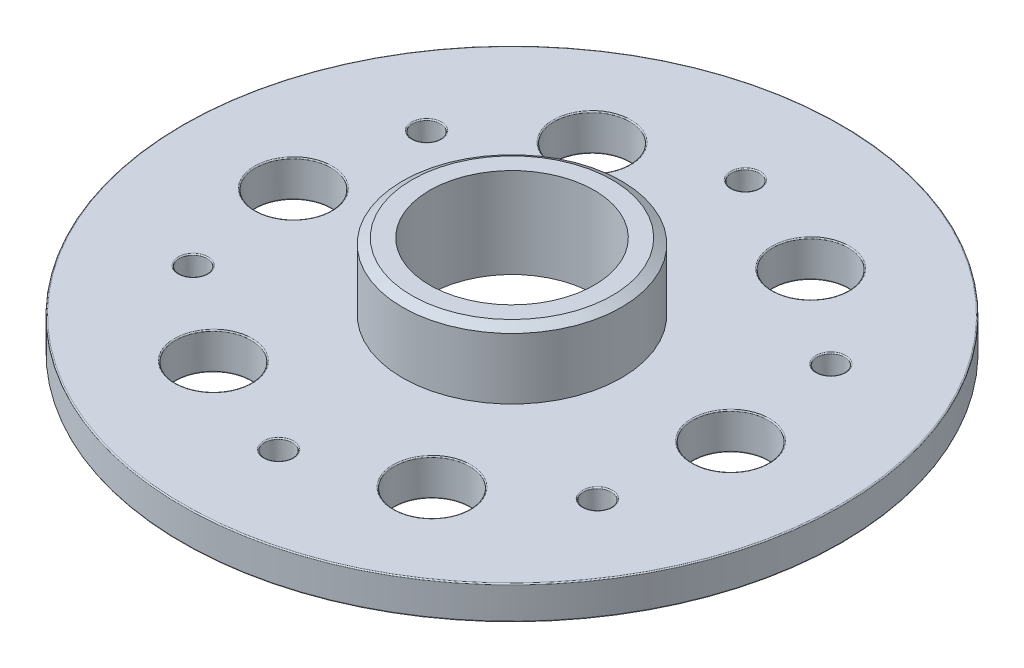
from build123d import *

# Parameters (mm, degrees)
SKETCH_3_R          = 15
CUT_EXTRUDE_2_DEPTH = 0.2
SKETCH_4_R          = 1.25
SKETCH_4_R_2        = 3.4
CUT_EXTRUDE_3_DEPTH = 10.3
FILLET_3_R          = 0.1


with BuildPart() as part:
    # Эскиз1 → Повернуть1 (revolve)
    with BuildSketch(Plane.XY):
        Polygon((-9.85, 14), (-9.85, 19.5), (-9.018203137, 20), (-7.4, 20), (-7.4, 11.9), (-9, 11.9), (-9, 10.7), (-24.5, 10.7), (-29.65, 11), (-29.65, 14), align=None)
    revolve(axis=Axis((0, 73.864195873, 0), (0, -1, 0)))

    # Эскиз3 → Вырез-Вытянуть2 (cut)
    with BuildSketch(Plane.XZ.offset(-10.7)):
        Circle(SKETCH_3_R)
    extrude(amount=-CUT_EXTRUDE_2_DEPTH, mode=Mode.SUBTRACT)

    # Эскиз4 → Вырез-Вытянуть3 (cut, through all)
    with BuildSketch(Plane.XZ.offset(-10.7)):
        with Locations((0, 21)):
            Circle(SKETCH_4_R)
        with Locations((18.186533479, 10.5)):
            Circle(SKETCH_4_R)
        with Locations((18.186533479, -10.5)):
            Circle(SKETCH_4_R)
        with Locations((0, -21)):
            Circle(SKETCH_4_R)
        with Locations((-18.186533479, -10.5)):
            Circle(SKETCH_4_R)
        with Locations((-18.186533479, 10.5)):
            Circle(SKETCH_4_R)
        with Locations((19.667526395, 0)):
            Circle(SKETCH_4_R_2)
        with Locations((9.833763197, -17.032577487)):
            Circle(SKETCH_4_R_2)
        with Locations((-9.833763197, -17.032577487)):
            Circle(SKETCH_4_R_2)
        with Locations((-19.667526395, 0)):
            Circle(SKETCH_4_R_2)
        with Locations((-9.833763197, 17.032577487)):
            Circle(SKETCH_4_R_2)
        with Locations((9.833763197, 17.032577487)):
            Circle(SKETCH_4_R_2)
    extrude(amount=-CUT_EXTRUDE_3_DEPTH, mode=Mode.SUBTRACT)

    # Скругление3
    fillet_3_edges = [part.edges().sort_by_distance(p)[0] for p in [
        (-1.25, 14, 21),
        (-1.25, 10.7, 21),
        (16.267526395, 14, 0),
        (16.267526395, 10.7, 0),
        (16.936533479, 14, 10.5),
        (16.936533479, 10.7, 10.5),
        (16.936533479, 14, -10.5),
        (16.936533479, 10.7, -10.5),
        (-1.25, 14, -21),
        (-1.25, 10.7, -21),
        (-19.436533479, 14, -10.5),
        (-19.436533479, 10.7, -10.5),
        (-19.436533479, 14, 10.5),
        (-19.436533479, 10.7, 10.5),
        (6.433763197, 14, -17.032577487),
        (6.433763197, 10.7, -17.032577487),
        (-13.233763197, 14, -17.032577487),
        (-13.233763197, 10.7, -17.032577487),
        (-23.067526395, 14, 0),
        (-23.067526395, 10.7, 0),
        (-13.233763197, 14, 17.032577487),
        (-13.233763197, 10.7, 17.032577487),
        (6.433763197, 14, 17.032577487),
        (6.433763197, 10.7, 17.032577487),
        (29.65, 14, 0),
        (29.65, 11, 0),
    ]]
    fillet(fillet_3_edges, radius=FILLET_3_R)


solid = part.part
